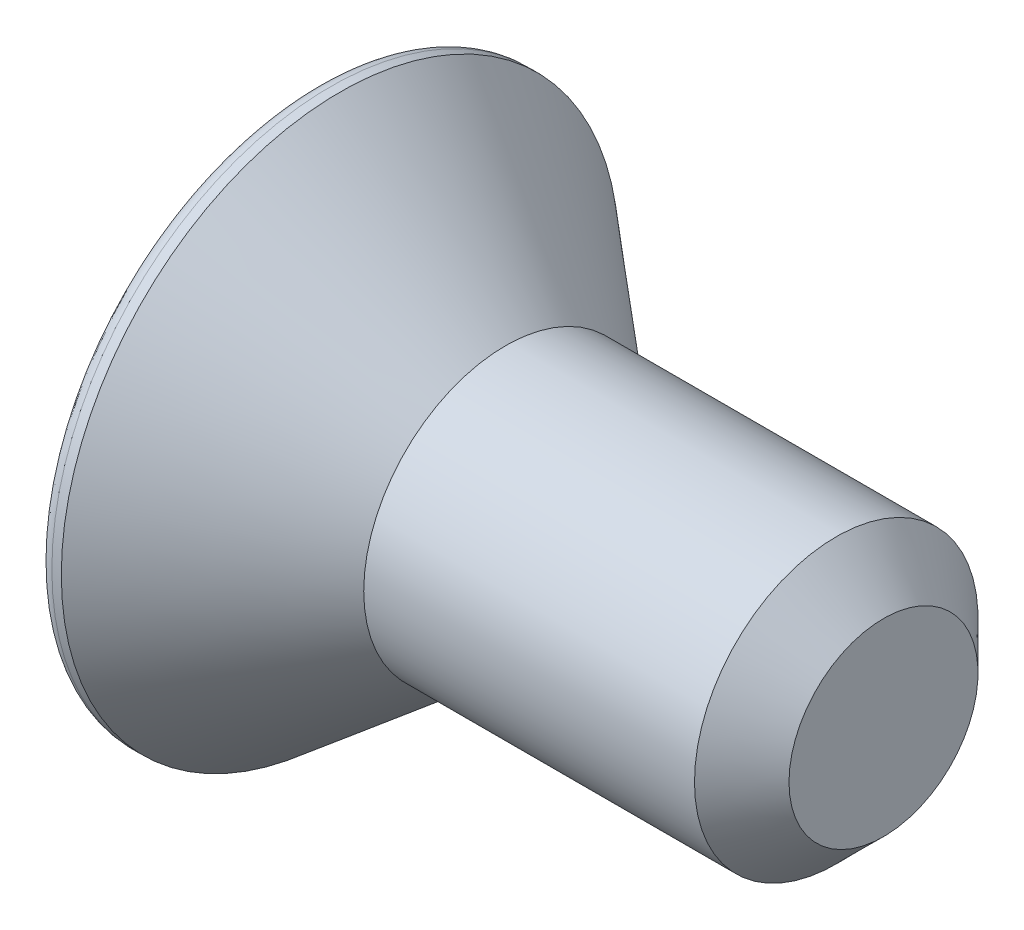
from build123d import *

# Parameters (mm, degrees)
CUT_EXTRUDE_1_DEPTH = 3
FILLET_1_R          = 0.3
CHAMFER_1_SIZE      = 1


with BuildPart() as part:
    # Эскиз1 → Повернуть1 (revolve)
    with BuildSketch(Plane.XY, mode=Mode.PRIVATE) as revolve_1_sk:
        Polygon((0, 0), (0, 5.9), (0.5, 5.9), (4, 3), (12, 3), (12, 0), align=None)
    revolve(revolve_1_sk.sketch.rotate(Axis((0, 0, 0), (1, 0, 0)), 90), axis=Axis((0, 0, 0), (1, 0, 0)))  # turned: the seam where the file's is

    # Эскиз2 → Вырез-Вытянуть1 (cut)
    with BuildSketch(Plane.ZY):
        Polygon((1.154700538, 2), (-1.154700538, 2), (-2.309401077, 0), (-1.154700538, -2), (1.154700538, -2), (2.309401077, 0), align=None)
    extrude(amount=-CUT_EXTRUDE_1_DEPTH, mode=Mode.SUBTRACT)

    # Скругление1
    fillet_1_edges = [part.edges().sort_by_distance(p)[0] for p in [
        (0, 0, -5.9),
    ]]
    fillet(fillet_1_edges, radius=FILLET_1_R)

    # Фаска1
    chamfer_1_edges = [part.edges().sort_by_distance(p)[0] for p in [
        (12, 0, -3),
    ]]
    chamfer(chamfer_1_edges, length=CHAMFER_1_SIZE)


solid = part.part
